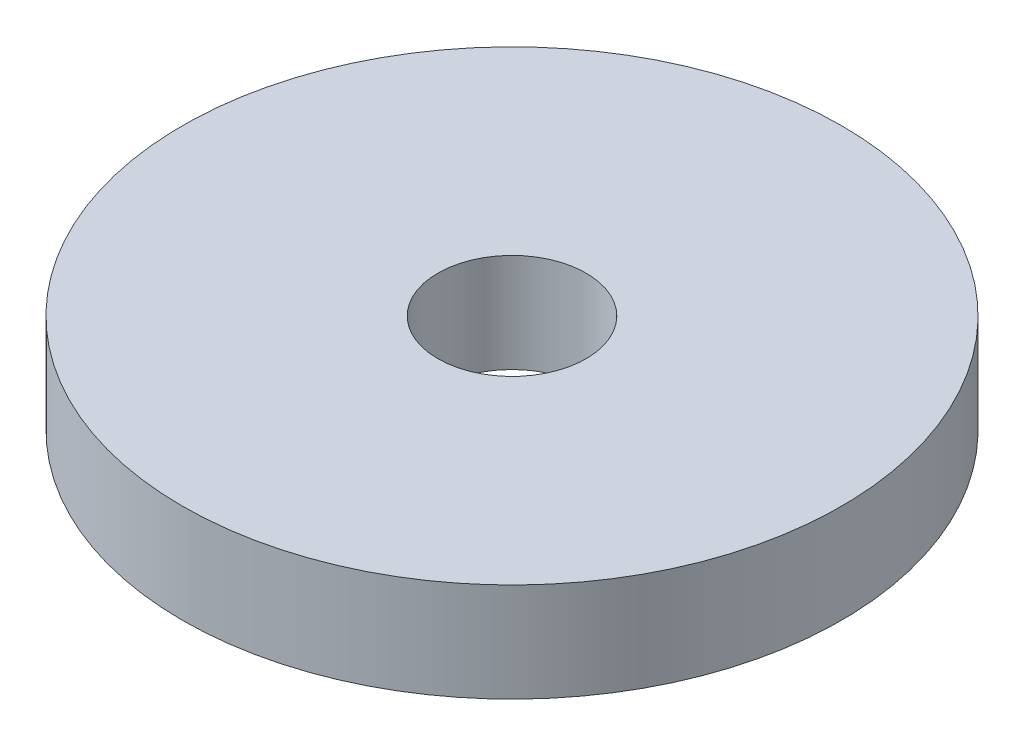
from build123d import *

# Parameters (mm, degrees)
SKETCH1_R           = 10
SKETCH1_R_2         = 2.25
BOSS_EXTRUDE1_DEPTH = 3


with BuildPart() as part:
    # Sketch1 → Boss-Extrude1 (new body)
    with BuildSketch(Plane(origin=(0, 0, 0), x_dir=(1, 0, 0), z_dir=(0, 1, 0))):
        Circle(SKETCH1_R)
        Circle(SKETCH1_R_2, mode=Mode.SUBTRACT)
    extrude(amount=BOSS_EXTRUDE1_DEPTH)


solid = part.part
